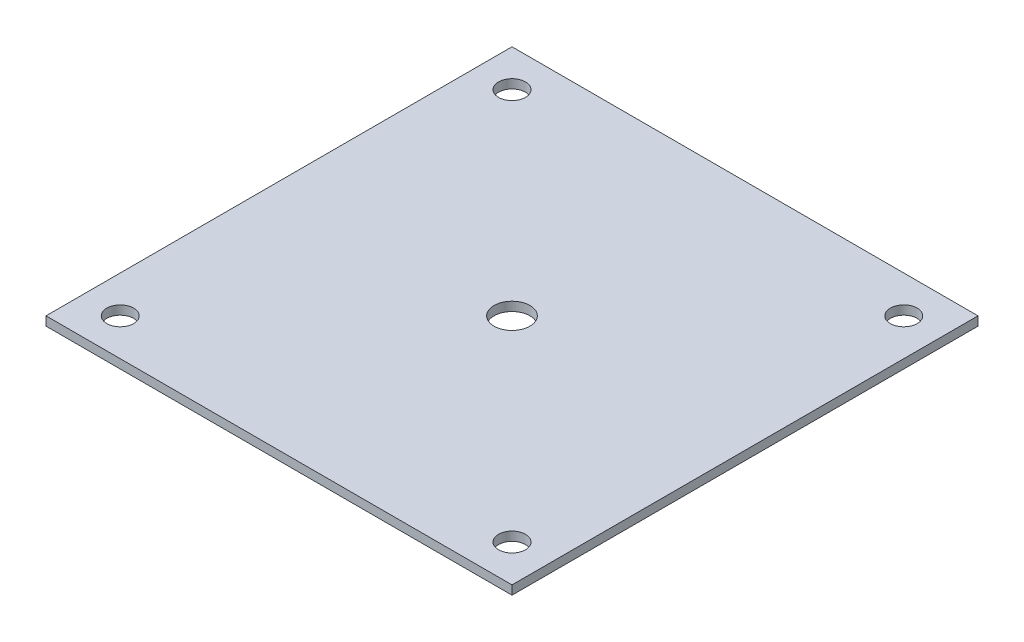
from build123d import *

# Parameters (mm, degrees)
SKETCH1_W      = 165.1
SKETCH1_H      = 165.1
SKETCH1_R      = 6.35
SKETCH1_R_2    = 4.7625
EXTRUDE1_DEPTH = 3.175


with BuildPart() as part:
    # Sketch1 → Extrude1 (new body)
    with BuildSketch(Plane(origin=(0, 0, 0), x_dir=(1, 0, 0), z_dir=(0, 1, 0))):
        Rectangle(SKETCH1_W, SKETCH1_H)
        Circle(SKETCH1_R, mode=Mode.SUBTRACT)
        with Locations((-69.40042, 69.40042)):
            Circle(SKETCH1_R_2, mode=Mode.SUBTRACT)
        with Locations((69.40042, 69.40042)):
            Circle(SKETCH1_R_2, mode=Mode.SUBTRACT)
        with Locations((69.40042, -69.40042)):
            Circle(SKETCH1_R_2, mode=Mode.SUBTRACT)
        with Locations((-69.40042, -69.40042)):
            Circle(SKETCH1_R_2, mode=Mode.SUBTRACT)
    extrude(amount=-EXTRUDE1_DEPTH)


solid = part.part
